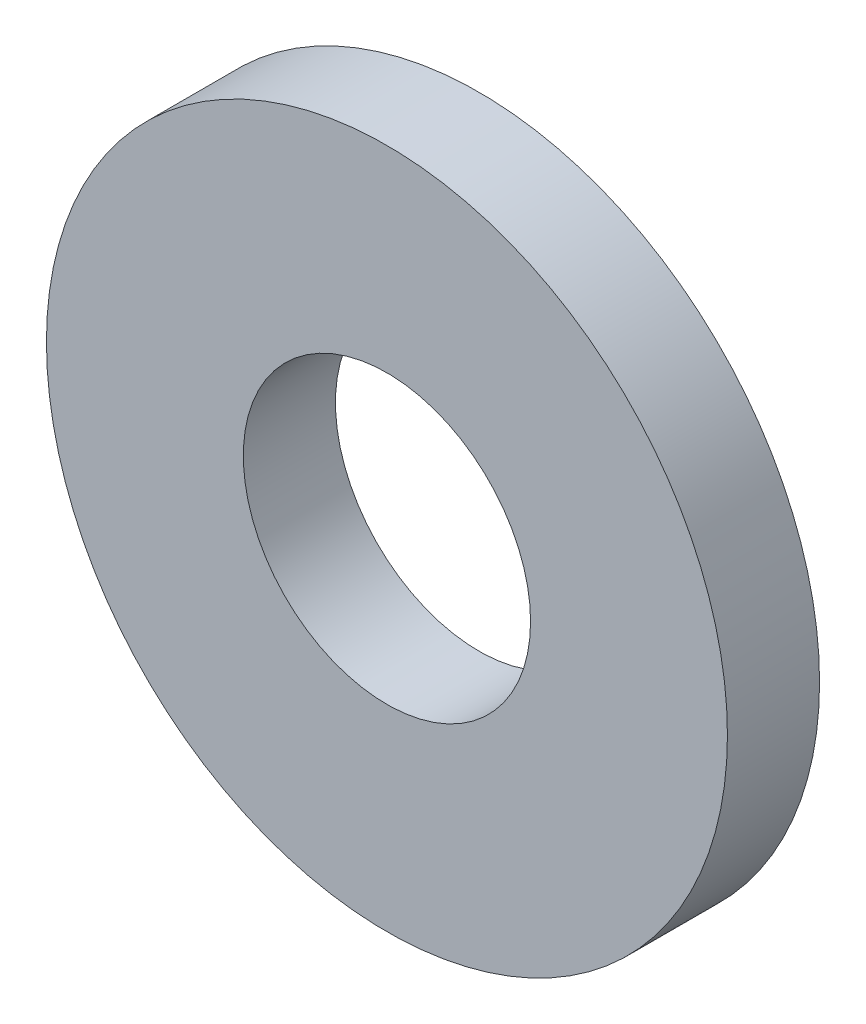
from build123d import *

# Parameters (mm, degrees)
SKETCH1_R      = 8.73125
SKETCH1_R_2    = 3.683
EXTRUDE1_DEPTH = 2.3622


with BuildPart() as part:
    # Sketch1 → Extrude1 (new body)
    with BuildSketch(Plane.XY):
        Circle(SKETCH1_R)
        Circle(SKETCH1_R_2, mode=Mode.SUBTRACT)
    extrude(amount=-EXTRUDE1_DEPTH)


solid = part.part
